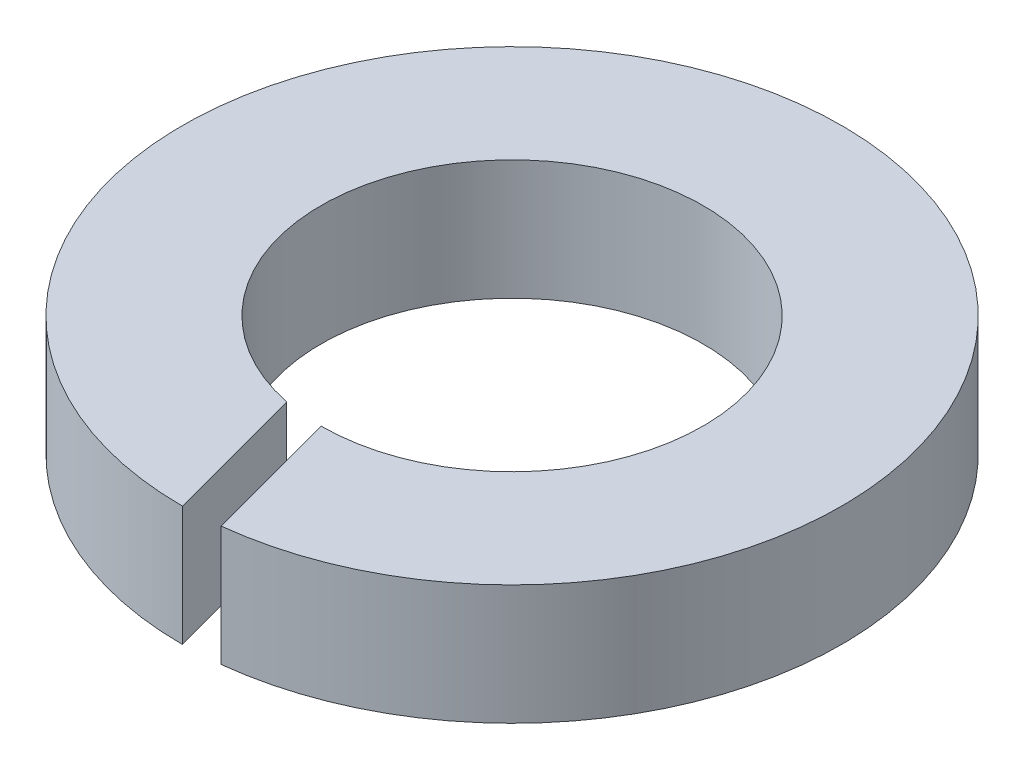
from build123d import *

# Parameters (mm, degrees)
SKETCH_1_R               = 4.4
SKETCH_1_R_2             = 2.55
EXTRUDE_1_DEPTH          = 1.6
CUT_EXTRUDE_1_DEPTH      = 1
CUT_EXTRUDE_1_DEPTH_BACK = 2.6


with BuildPart() as part:
    # Эскиз1 → Бобышка-Вытянуть1 (new body)
    with BuildSketch(Plane(origin=(0, 0, 0), x_dir=(1, 0, 0), z_dir=(0, 1, 0))):
        Circle(SKETCH_1_R)
        Circle(SKETCH_1_R_2, mode=Mode.SUBTRACT)
    extrude(amount=EXTRUDE_1_DEPTH)

    # Эскиз2 → Вырез-Вытянуть1 (cut, two sides)
    with BuildSketch(Plane(origin=(0, 1.6, 0), x_dir=(1, 0, 0), z_dir=(0, 1, 0))) as cut_extrude_1_sk:
        with BuildLine():
            Line((0, -4.4), (-0.509482587, -2.498585098))
            ThreePointArc((-0.509482587, -2.498585098), (-0.256035153, -2.537113714), (0, -2.55))
            Line((0, -2.55), (0.488419817, -4.372807574))
            ThreePointArc((0.488419817, -4.372807574), (0.244588096, -4.393196634), (0, -4.4))
        make_face()
    extrude(amount=CUT_EXTRUDE_1_DEPTH, mode=Mode.SUBTRACT)
    extrude(cut_extrude_1_sk.sketch, amount=-CUT_EXTRUDE_1_DEPTH_BACK, mode=Mode.SUBTRACT)


solid = part.part
